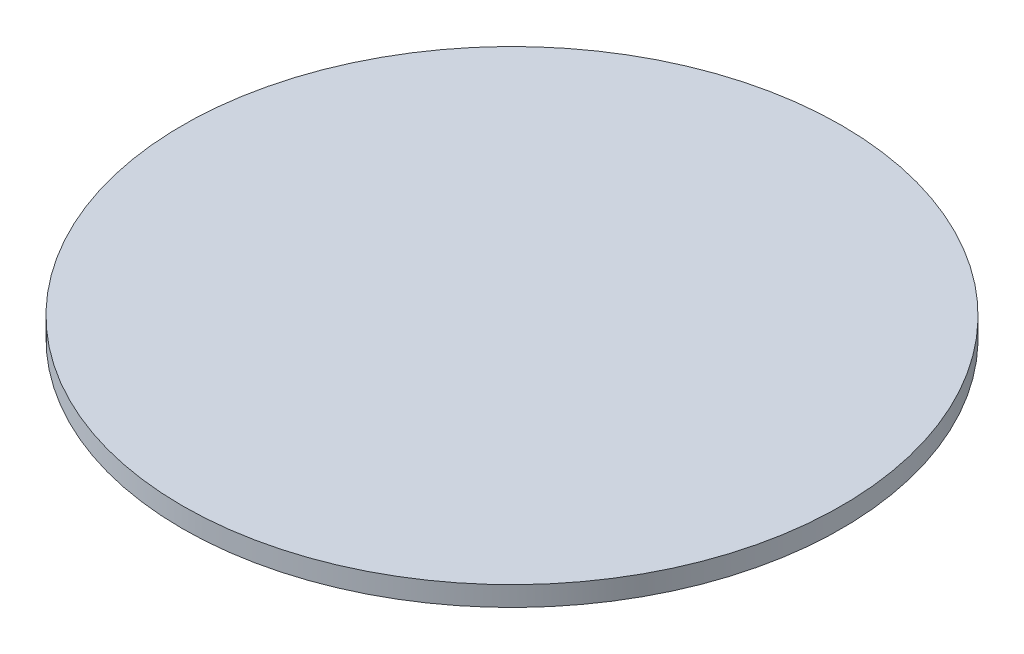
from build123d import *

# Parameters (mm, degrees)
SKETCH1_R           = 12.7
BOSS_EXTRUDE1_DEPTH = 0.762


with BuildPart() as part:
    # Sketch1 → Boss-Extrude1 (new body)
    with BuildSketch(Plane(origin=(0, 0, 0), x_dir=(1, 0, 0), z_dir=(0, 1, 0))):
        Circle(SKETCH1_R)
    extrude(amount=BOSS_EXTRUDE1_DEPTH)


solid = part.part
